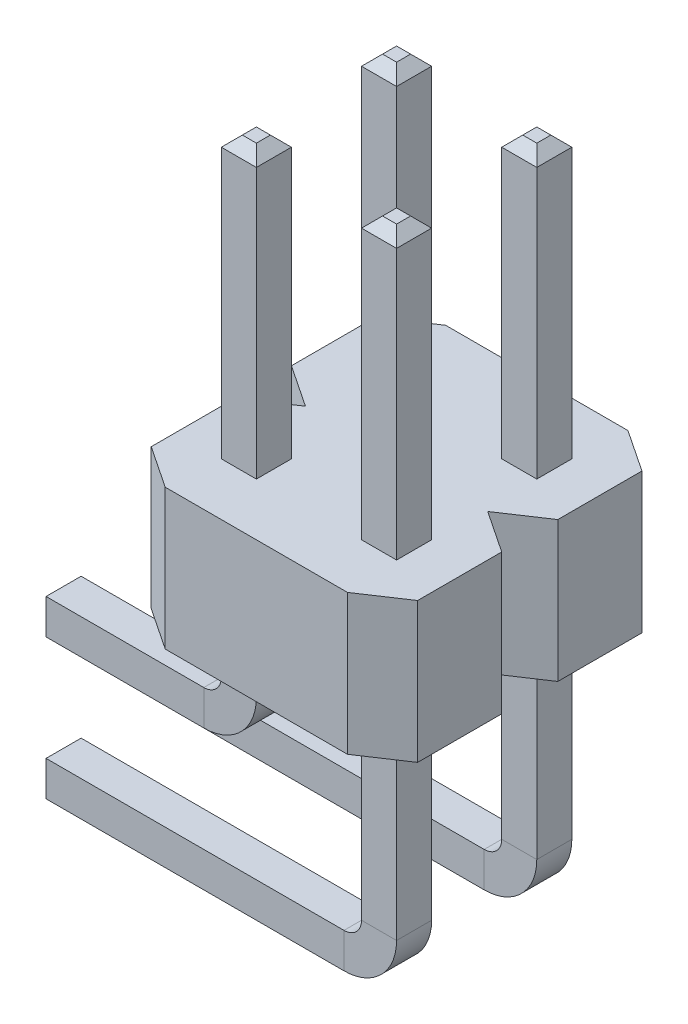
from build123d import *

# Parameters (mm, degrees)
BOSS_EXTRUDE2_DEPTH = 2.54
SKETCH5_W           = 0.635
SKETCH5_H           = 0.635
SKETCH6_W           = 0.635
SKETCH6_H           = 0.635
CHAMFER1_SIZE       = 0.1905


with BuildPart() as part:
    # Sketch1 → Boss-Extrude2 (new body)
    with BuildSketch(Plane(origin=(0, 0, 0), x_dir=(1, 0, 0), z_dir=(0, 1, 0))):
        Polygon((-2.413, -0.762), (-1.651, -1.27), (1.651, -1.27), (2.413, -0.762), (2.413, 0.762), (1.651, 1.27), (-1.651, 1.27), (-2.413, 0.762), align=None)
    extrude(amount=BOSS_EXTRUDE2_DEPTH)

    # Sweep5: sweep along a path in Sketch2
    with BuildLine(Plane.XY) as sweep5_path:
        Line((-1.27, 7.62), (-1.27, 2.54))
        Line((-1.27, 2.54), (-1.27, -0.889))
        ThreePointArc((-1.27, -0.889), (-1.455987194, -1.338012806), (-1.905, -1.524))
        Line((-1.905, -1.524), (-4.953, -1.524))
    # Sketch5 → Sweep5 (sweep)
    with BuildSketch(Plane(origin=(0, 7.62, 0), x_dir=(1, 0, 0), z_dir=(0, 1, 0))):
        with Locations((-1.27, 0)):
            Rectangle(SKETCH5_W, SKETCH5_H)
    sweep(path=sweep5_path.line)

    # Sweep6: sweep along a path in Sketch7
    with BuildLine(Plane.XY) as sweep6_path:
        Line((-4.953, -4.064), (0.635, -4.064))
        ThreePointArc((0.635, -4.064), (1.084012806, -3.878012806), (1.27, -3.429))
        Line((1.27, -3.429), (1.27, 2.54))
        Line((1.27, 2.54), (1.27, 7.62))
    # Sketch6 → Sweep6 (sweep)
    with BuildSketch(Plane(origin=(0, 7.62, 0), x_dir=(1, 0, 0), z_dir=(0, 1, 0))):
        with Locations((1.27, 0)):
            Rectangle(SKETCH6_W, SKETCH6_H)
    sweep(path=sweep6_path.line)

    # Chamfer1
    chamfer1_edges = [part.edges().sort_by_distance(p)[0] for p in [
        (-4.953, -1.524, -0.3175),
        (-4.953, -1.8415, 0),
        (-4.953, -1.524, 0.3175),
        (-4.953, -1.2065, 0),
        (-1.27, 7.62, -0.3175),
        (-0.9525, 7.62, 0),
        (-1.27, 7.62, 0.3175),
        (-1.5875, 7.62, 0),
        (1.5875, 7.62, 0),
        (1.27, 7.62, -0.3175),
        (0.9525, 7.62, 0),
        (1.27, 7.62, 0.3175),
        (-4.953, -4.3815, 0),
        (-4.953, -4.064, -0.3175),
        (-4.953, -3.7465, 0),
        (-4.953, -4.064, 0.3175),
    ]]
    chamfer(chamfer1_edges, length=CHAMFER1_SIZE)

    # Mirror1: part across plane


with BuildPart() as part_1:
    add(part.part)
    add(part.part.mirror(Plane(origin=(-1.651, 2.54, -1.27), x_dir=(1, 0, 0), z_dir=(0, 0, 1))))


solid = part_1.part
